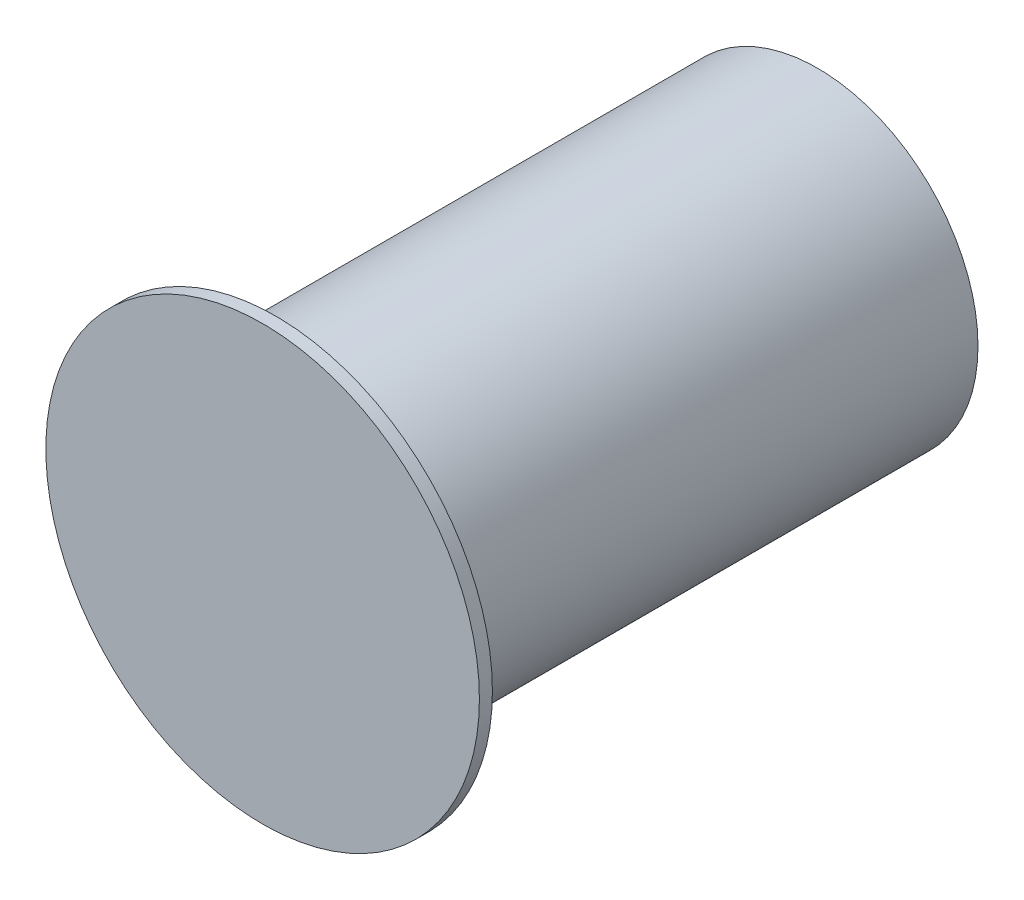
from build123d import *

# Parameters (mm, degrees)
SKETCH2_R           = 10
BOSS_EXTRUDE1_DEPTH = 0.6
SKETCH3_R           = 7.4
BOSS_EXTRUDE2_DEPTH = 25
SKETCH4_R           = 5
CUT_EXTRUDE1_DEPTH  = 2
SKETCH5_R           = 3
CUT_EXTRUDE2_DEPTH  = 2.5
CUT_EXTRUDE3_DEPTH  = 7


with BuildPart() as part:
    # Sketch2 → Boss-Extrude1 (new body)
    with BuildSketch(Plane.XY):
        Circle(SKETCH2_R)
    extrude(amount=BOSS_EXTRUDE1_DEPTH)

    # Sketch3 → Boss-Extrude2 (add)
    with BuildSketch(Plane(origin=(0, 0, 0), x_dir=(-1, 0, 0), z_dir=(0, 0, -1))):
        Circle(SKETCH3_R)
    extrude(amount=BOSS_EXTRUDE2_DEPTH)

    # Sketch4 → Cut-Extrude1 (cut)
    with BuildSketch(Plane(origin=(0, 0, -25), x_dir=(-1, 0, 0), z_dir=(0, 0, -1))):
        Circle(SKETCH4_R)
    extrude(amount=-CUT_EXTRUDE1_DEPTH, mode=Mode.SUBTRACT)

    # Sketch5 → Cut-Extrude2 (cut)
    with BuildSketch(Plane(origin=(0, 0, -23), x_dir=(-1, 0, 0), z_dir=(0, 0, -1))):
        Circle(SKETCH5_R)
    extrude(amount=-CUT_EXTRUDE2_DEPTH, mode=Mode.SUBTRACT)

    # Sketch6 → Cut-Extrude3 (cut)
    with BuildSketch(Plane(origin=(0, 0, -20.5), x_dir=(-1, 0, 0), z_dir=(0, 0, -1))):
        with BuildLine():
            Line((-2, 2.236067977), (-2, -2.236067977))
            ThreePointArc((-2, -2.236067977), (0, -3), (2, -2.236067977))
            Line((2, -2.236067977), (2, 2.236067977))
            ThreePointArc((2, 2.236067977), (0, 3), (-2, 2.236067977))
        make_face()
    extrude(amount=-CUT_EXTRUDE3_DEPTH, mode=Mode.SUBTRACT)


solid = part.part
